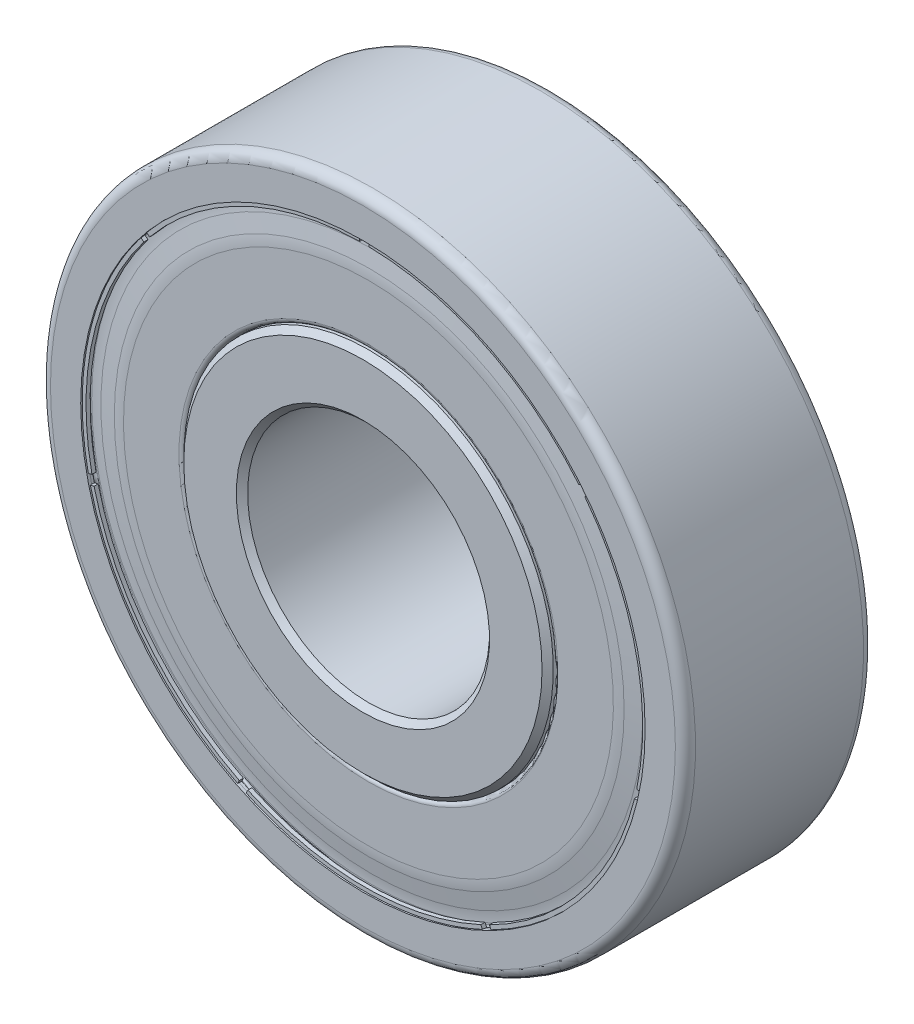
from build123d import *

# Parameters (mm, degrees)
CHAMFER1_SIZE      = 0.21
FILLET1_R          = 2.4
CIRPATTERN1_COUNT  = 7
CUT_EXTRUDE1_REACH = 20.338
CIRPATTERN2_COUNT  = 7


with BuildPart() as part:
    # Sketch3 → Revolve1 (revolve)
    with BuildSketch(Plane(origin=(0, 0, 0), x_dir=(0, 0, -1), z_dir=(1, 0, 0)), mode=Mode.PRIVATE) as revolve1_sk:
        with BuildLine():
            Line((-3.5, 4.5), (3.5, 4.5))
            Line((3.5, 4.5), (3.5, 6.875))
            Line((3.5, 6.875), (1.224744871, 6.875))
            ThreePointArc((1.224744871, 6.875), (0, 6.5), (-1.224744871, 6.875))
            Line((-1.224744871, 6.875), (-3.5, 6.875))
            Line((-3.5, 6.875), (-3.5, 4.5))
        make_face()
        with BuildLine():
            Line((3.5, 10.5), (3.395, 10.5))
            ThreePointArc((3.395, 10.5), (3.235252255, 10.674334072), (3.047658643, 10.530388431))
            Line((3.047658643, 10.530388431), (2.936504154, 9.9))
            Line((2.936504154, 9.9), (1.820714146, 9.9))
            ThreePointArc((1.820714146, 9.9), (0, 10.875), (-1.820714146, 9.9))
            Line((-1.820714146, 9.9), (-2.936504154, 9.9))
            Line((-2.936504154, 9.9), (-3.047658643, 10.530388431))
            ThreePointArc((-3.047658643, 10.530388431), (-3.235252255, 10.674334072), (-3.395, 10.5))
            Line((-3.395, 10.5), (-3.5, 10.5))
            Line((-3.5, 10.5), (-3.5, 11.625))
            ThreePointArc((-3.5, 11.625), (-3.390165043, 11.890165043), (-3.125, 12))
            Line((-3.125, 12), (3.125, 12))
            ThreePointArc((3.125, 12), (3.390165043, 11.890165043), (3.5, 11.625))
            Line((3.5, 11.625), (3.5, 10.5))
        make_face()
    revolve(revolve1_sk.sketch.rotate(Axis((0, 0, 3.5), (0, 0, -1)), 180), axis=Axis((0, 0, 3.5), (0, 0, -1)))

    # Chamfer1
    chamfer1_edges = [part.edges().sort_by_distance(p)[0] for p in [
        (0, 6.875, 3.5),
        (0, 6.875, -3.5),
        (0, 4.5, -3.5),
        (0, 4.5, 3.5),
    ]]
    chamfer(chamfer1_edges, length=CHAMFER1_SIZE)


with BuildPart() as body_2:
    # Sketch4 → Revolve2 (revolve)
    with BuildSketch(Plane(origin=(0, 0, 0), x_dir=(0, 0, -1), z_dir=(1, 0, 0)), mode=Mode.PRIVATE) as revolve2_sk:
        with BuildLine():
            Line((-3.395, 10.5), (-3.4475, 10.5))
            Line((-3.4475, 10.5), (-3.4475, 10.356))
            Line((-3.4475, 10.356), (-3.295, 10.356))
            Line((-3.295, 10.356), (-3.295, 10.5))
            ThreePointArc((-3.295, 10.5), (-3.22, 10.575), (-3.145, 10.5))
            Line((-3.145, 10.5), (-3.145, 10.26))
            Line((-3.145, 10.26), (-3.295, 9.3))
            Line((-3.295, 9.3), (-3.295, 7.05))
            ThreePointArc((-3.295, 7.05), (-3.243743687, 6.926256313), (-3.12, 6.875))
            Line((-3.12, 6.875), (-2.128333333, 6.875))
            Line((-2.128333333, 6.875), (-2.128333333, 6.975))
            Line((-2.128333333, 6.975), (-3.12, 6.975))
            ThreePointArc((-3.12, 6.975), (-3.173033009, 6.996966991), (-3.195, 7.05))
            Line((-3.195, 7.05), (-3.195, 9.3))
            Line((-3.195, 9.3), (-3.045, 10.26))
            Line((-3.045, 10.26), (-3.045, 10.5))
            ThreePointArc((-3.045, 10.5), (-3.22, 10.675), (-3.395, 10.5))
        make_face()
    revolve(revolve2_sk.sketch.rotate(Axis((0, 0, 3.5), (0, 0, -1)), 180), axis=Axis((0, 0, 3.5), (0, 0, -1)))

    # Fillet1
    fillet1_edges = [body_2.edges().sort_by_distance(p)[0] for p in [
        (0, 9.3, 3.295),
        (0, 10.26, 3.145),
    ]]
    fillet(fillet1_edges, radius=FILLET1_R)

    # Cut-Extrude1: up to this face of the body (flat: up to its plane)
    cut_extrude1_end = Plane(body_2.part.faces().sort_by_distance((0, 10.385698485, 3.295))[0])
    # Sketch6 → Cut-Extrude1 (cut, up to the picked face)
    with BuildSketch(Plane.XY.offset(3.4475), mode=Mode.PRIVATE) as cut_extrude1_sk1:
        with BuildLine():
            Line((-0.175, 10.498541565), (-0.175, 10.354521283))
            ThreePointArc((-0.175, 10.354521283), (0, 10.356), (0.175, 10.354521283))
            Line((0.175, 10.354521283), (0.175, 10.498541565))
            ThreePointArc((0.175, 10.498541565), (0, 10.5), (-0.175, 10.498541565))
        make_face()
    cut_extrude1_tool1 = split(extrude(cut_extrude1_sk1.sketch, amount=-CUT_EXTRUDE1_REACH, mode=Mode.PRIVATE), bisect_by=cut_extrude1_end, keep=Keep.BOTH, mode=Mode.PRIVATE)
    cut_extrude1 = cut_extrude1_tool1.solids().sort_by(Axis((0, 10.42751, 3.4475), (0, 0, -1)))[0]
    add(cut_extrude1, mode=Mode.SUBTRACT)

    # CirPattern2: Cut-Extrude1 ×7 about axis
    cirpattern2_axis = Axis((0, 0, 0), (0, 0, 1))
    for i in range(1, CIRPATTERN2_COUNT):
        add(cut_extrude1.rotate(cirpattern2_axis, i * 360 / CIRPATTERN2_COUNT), mode=Mode.SUBTRACT)


with BuildPart() as body_3:
    # Sketch5 → Revolve3 (revolve)
    with BuildSketch(Plane(origin=(0, 0, 0), x_dir=(0, 0, -1), z_dir=(1, 0, 0))):
        with BuildLine():
            Line((0, 10.875), (0, 6.5))
            ThreePointArc((0, 6.5), (2.1875, 8.6875), (0, 10.875))
        make_face()
    revolve(axis=Axis((0, 10.875, 0), (0, -1, 0)))


with BuildPart() as cirpattern1_1:
    # CirPattern1: pattern copy
    add(body_3.part.rotate(Axis((0, 0, 0), (0, 0, 1)), 1 * 360 / CIRPATTERN1_COUNT))


with BuildPart() as cirpattern1_2:
    # CirPattern1: pattern copy
    add(body_3.part.rotate(Axis((0, 0, 0), (0, 0, 1)), 2 * 360 / CIRPATTERN1_COUNT))


with BuildPart() as cirpattern1_3:
    # CirPattern1: pattern copy
    add(body_3.part.rotate(Axis((0, 0, 0), (0, 0, 1)), 3 * 360 / CIRPATTERN1_COUNT))


with BuildPart() as cirpattern1_4:
    # CirPattern1: pattern copy
    add(body_3.part.rotate(Axis((0, 0, 0), (0, 0, 1)), 4 * 360 / CIRPATTERN1_COUNT))


with BuildPart() as cirpattern1_5:
    # CirPattern1: pattern copy
    add(body_3.part.rotate(Axis((0, 0, 0), (0, 0, 1)), 5 * 360 / CIRPATTERN1_COUNT))


with BuildPart() as cirpattern1_6:
    # CirPattern1: pattern copy
    add(body_3.part.rotate(Axis((0, 0, 0), (0, 0, 1)), 6 * 360 / CIRPATTERN1_COUNT))


with BuildPart() as body_10:
    # Mirror2: mirrored copy
    add(body_2.part.mirror(Plane.XY))


solid = Compound([part.part, body_2.part, body_3.part, cirpattern1_1.part, cirpattern1_2.part, cirpattern1_3.part, cirpattern1_4.part, cirpattern1_5.part, cirpattern1_6.part, body_10.part])
